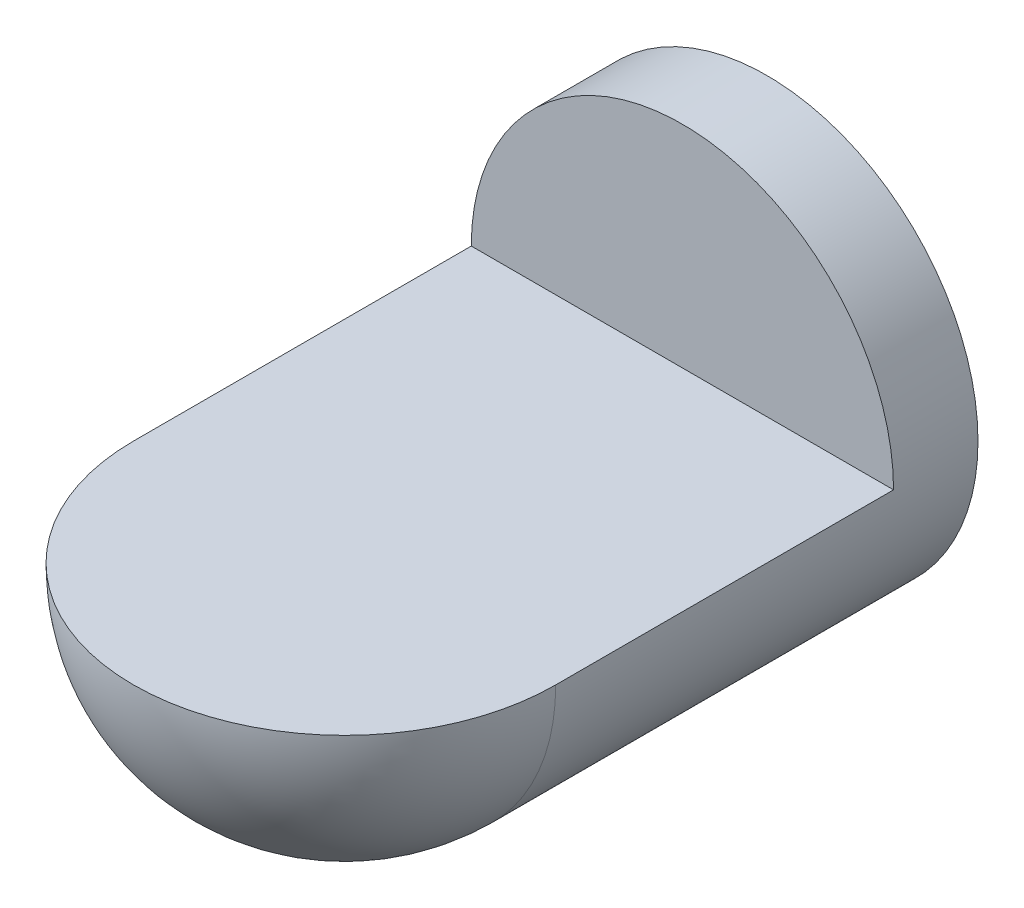
from build123d import *

# Parameters (mm, degrees)
CUT_EXTRUDE1_DEPTH      = 184.711730709
CUT_EXTRUDE1_DEPTH_BACK = 184.711730709


with BuildPart() as part:
    # Sketch1 → Revolve1 (revolve)
    with BuildSketch(Plane(origin=(0, 0, 0), x_dir=(0, 0, -1), z_dir=(1, 0, 0))):
        with BuildLine():
            Line((150, 0), (-75, 0))
            ThreePointArc((-75, 0), (-53.033008589, 53.033008589), (0, 75))
            Line((0, 75), (150, 75))
            Line((150, 75), (150, 0))
        make_face()
    revolve(axis=Axis((0, 0, 146.909145291), (0, 0, -1)))

    # Sketch2 → Cut-Extrude1 (cut, two sides: drawn at the far end of the back side and taken through both)
    with BuildSketch(Plane(origin=(0, 0, 0), x_dir=(0, 0, -1), z_dir=(1, 0, 0)).offset(-CUT_EXTRUDE1_DEPTH_BACK)):
        with BuildLine():
            Line((120, 0), (120, 75))
            Line((120, 75), (0, 75))
            ThreePointArc((0, 75), (-53.033008589, 53.033008589), (-75, 0))
            Line((-75, 0), (120, 0))
        make_face()
    extrude(amount=CUT_EXTRUDE1_DEPTH + CUT_EXTRUDE1_DEPTH_BACK, mode=Mode.SUBTRACT)


solid = part.part
